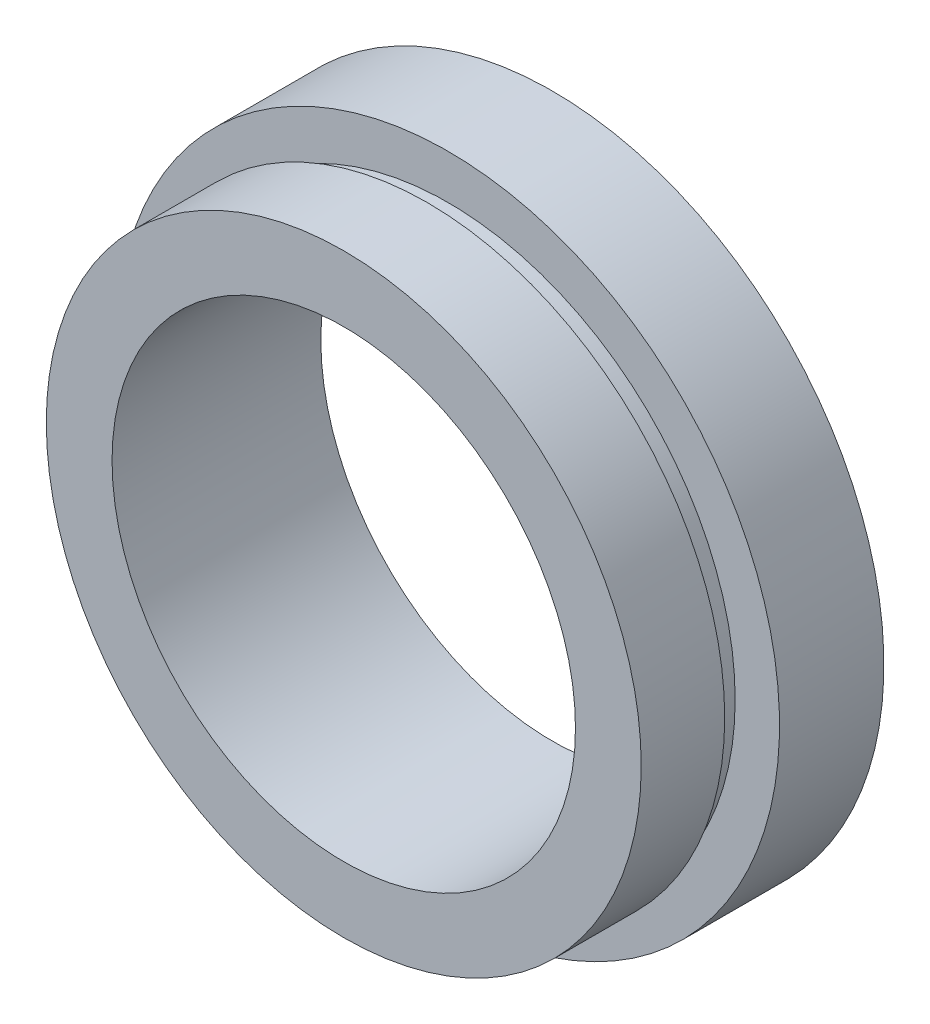
from build123d import *


with BuildPart() as part:
    # 草图1 → 旋转1 (revolve)
    with BuildSketch(Plane(origin=(0, 0, 0), x_dir=(1, 0, 0), z_dir=(0, 1, 0)), mode=Mode.PRIVATE) as revolve_1_sk:
        Polygon((11.1, 0), (11.1, 10), (15.875, 10), (15.875, 5), (13.75, 5), (13.75, 4), (14.25, 4), (14.25, 0), align=None)
    revolve(revolve_1_sk.sketch.rotate(Axis((0, 0, -19.14057971), (0, 0, 1)), 180), axis=Axis((0, 0, -19.14057971), (0, 0, 1)))  # turned: the seam where the file's is


solid = part.part
